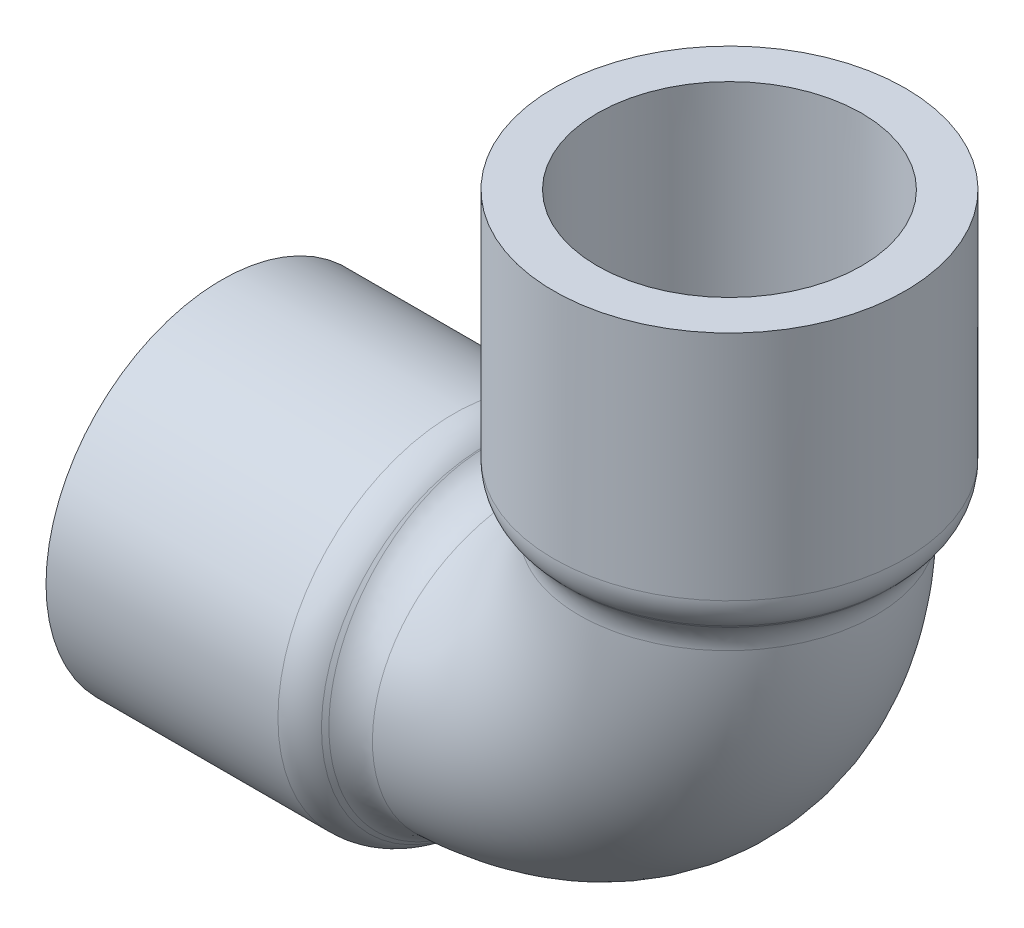
from build123d import *

# Parameters (mm, degrees)
SKETCH3_R   = 14.887575
SKETCH3_R_2 = 10.4648
FILLET1_R   = 4.422775


with BuildPart() as part:
    # Sketch1 → Revolve1 (revolve)
    with BuildSketch(Plane.XY):
        Polygon((-26.19375, -17.859375), (-23.22195, -14.887575), (-23.22195, -10.4648), (-26.19375, -13.2842), (-51.59375, -13.4366), (-51.59375, -17.859375), align=None)
    revolve(axis=Axis((-51.59375, 0, 0), (1, 0, 0)))



with BuildPart() as body_2:
    # Sketch2 → Revolve2 (revolve)
    with BuildSketch(Plane.XY):
        Polygon((13.4366, 51.59375), (13.2842, 26.19375), (10.4648, 23.22195), (14.887575, 23.22195), (17.859375, 26.19375), (17.859375, 51.59375), align=None)
    revolve(axis=Axis((0, 0, 0), (0, 1, 0)))


with BuildPart() as part_1:
    add(part.part)

    add(body_2.part)  # Sweep1 merges body 2
    # Sweep1: sweep along a path in Sketch4
    with BuildLine(Plane.XY) as sweep1_path:
        ThreePointArc((-23.22195, 0), (-6.801551683, 6.801551683), (0, 23.22195))
    # Sketch3 → Sweep1 (sweep)
    with BuildSketch(Plane(origin=(-23.22195, 0, 0), x_dir=(0, 0, -1), z_dir=(1, 0, 0))):
        Circle(SKETCH3_R)
        Circle(SKETCH3_R_2, mode=Mode.SUBTRACT)
    sweep(path=sweep1_path.line)

    # Fillet1
    fillet1_edges = [part_1.edges().sort_by_distance(p)[0] for p in [
        (-23.22195, 10.527105238, 10.527105238),
        (-10.527105238, 23.22195, 10.527105238),
        (-17.859375, 26.19375, 0),
        (-26.19375, 17.859375, 0),
    ]]
    fillet(fillet1_edges, radius=FILLET1_R)


solid = part_1.part
